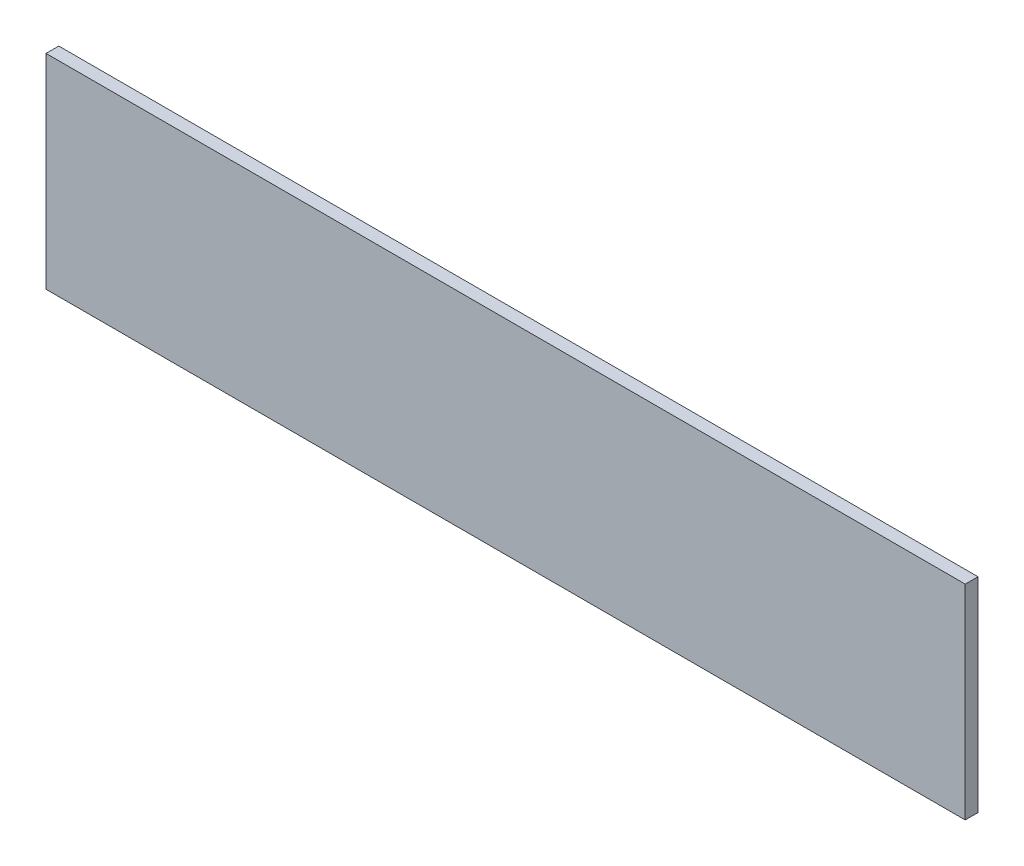
from build123d import *

# Parameters (mm, degrees)
SKETCH1_W           = 228.6
SKETCH1_H           = 50.8
BOSS_EXTRUDE1_DEPTH = 3.175


with BuildPart() as part:
    # Sketch1 → Boss-Extrude1 (new body)
    with BuildSketch(Plane.XY):
        with Locations((-114.3, -25.4)):
            Rectangle(SKETCH1_W, SKETCH1_H)
    extrude(amount=BOSS_EXTRUDE1_DEPTH)


solid = part.part
